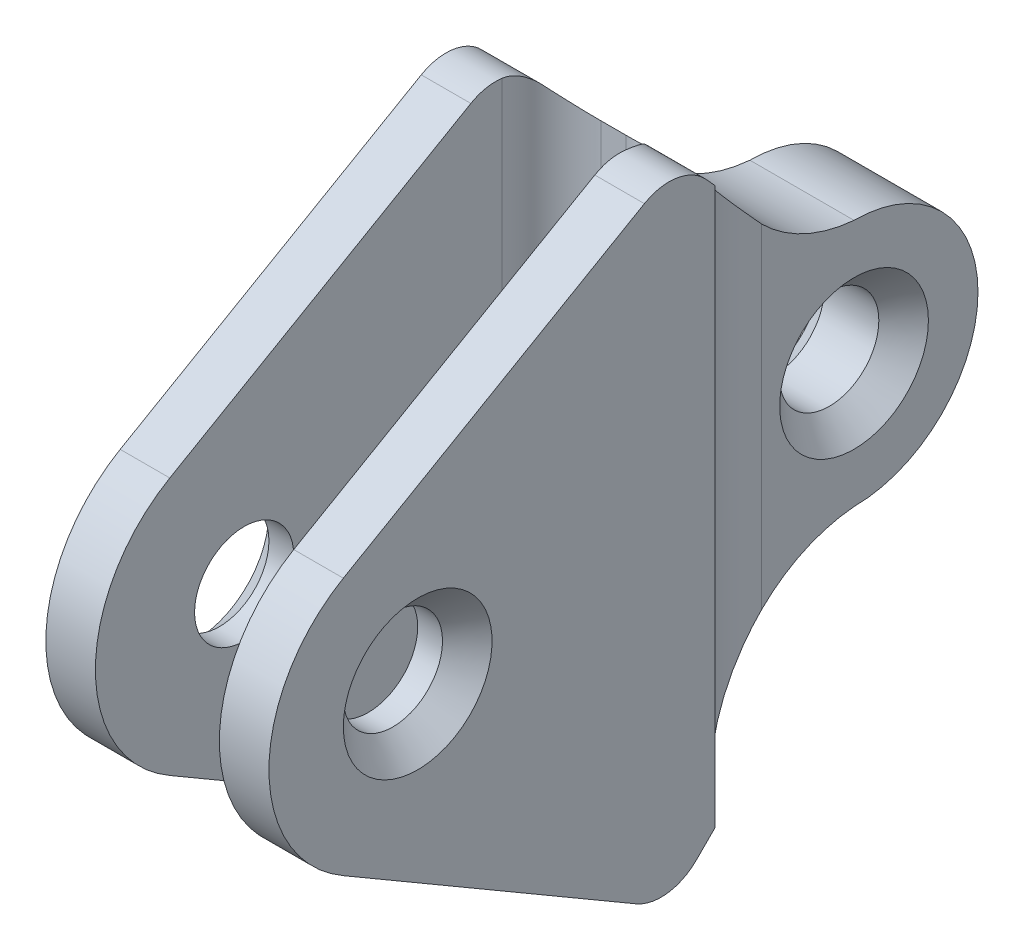
from build123d import *

# Parameters (mm, degrees)
BOSS_EXTRUDE1_DEPTH = 218
CUT_EXTRUDE1_DEPTH  = 218
CUT_EXTRUDE2_DEPTH  = 218
SKETCH6_R           = 10
CUT_EXTRUDE3_DEPTH  = 218
SKETCH7_R           = 10
CUT_EXTRUDE4_DEPTH  = 218
CHAMFER1_SIZE       = 5


with BuildPart() as part:
    # Sketch1 → Boss-Extrude1 (new body)
    with BuildSketch(Plane(origin=(0, 0, 0), x_dir=(1, 0, 0), z_dir=(0, 1, 0))):
        with BuildLine():
            Line((8, -63), (13, -63))
            ThreePointArc((13, -63), (20.071067812, -65.928932188), (23, -73))
            Line((23, -73), (23, -155))
            Line((23, -155), (33, -155))
            Line((33, -155), (33, -65))
            ThreePointArc((33, -65), (24.205505282, -55.89329221), (21, -43.645843496))
            Line((21, -43.645843496), (21, 0))
            Line((21, 0), (0, 0))
            Line((0, 0), (0, -43.645843496))
            ThreePointArc((0, -43.645843496), (-3.205505282, -55.89329221), (-12, -65))
            Line((-12, -65), (-12, -155))
            Line((-12, -155), (-2, -155))
            Line((-2, -155), (-2, -100.45062745))
            Line((-2, -100.45062745), (-2, -73))
            ThreePointArc((-2, -73), (0.928932188, -65.928932188), (8, -63))
        make_face()
    extrude(amount=BOSS_EXTRUDE1_DEPTH)

    # Sketch3 → Cut-Extrude1 (cut)
    with BuildSketch(Plane.ZY):
        with BuildLine():
            ThreePointArc((25, 138.56265757), (35.089663756, 141.253339953), (43.645843496, 147.239396639))
            Line((43.645843496, 147.239396639), (43.645843496, 218))
            Line((43.645843496, 218), (0, 218))
            Line((0, 218), (0, 113.56265757))
            ThreePointArc((0, 113.56265757), (7.32233047, 131.2403271), (25, 138.56265757))
        make_face()
        with BuildLine():
            ThreePointArc((25, 88.56265757), (7.32233047, 95.884988041), (0, 113.56265757))
            Line((0, 113.56265757), (0, 0))
            Line((0, 0), (43.645843496, 0))
            Line((43.645843496, 0), (43.645843496, 79.885918501))
            ThreePointArc((43.645843496, 79.885918501), (35.089663756, 85.871975187), (25, 88.56265757))
        make_face()
    extrude(amount=-CUT_EXTRUDE1_DEPTH, mode=Mode.SUBTRACT)

    # Sketch5 → Cut-Extrude2 (cut)
    with BuildSketch(Plane.ZY.offset(12)):
        with BuildLine():
            ThreePointArc((66.899192484, 172.697482901), (72.753620331, 175.835761562), (79.282746191, 174.613618416))
            Line((79.282746191, 174.613618416), (140, 139.558495585))
            ThreePointArc((140, 139.558495585), (150.980762114, 128.577733471), (155, 113.577733471))
            Line((155, 113.577733471), (155, 218))
            Line((155, 218), (65, 218))
            Line((65, 218), (65, 170.618220852))
            Line((65, 170.618220852), (66.899192484, 172.697482901))
        make_face()
        Polygon((43.645843496, 147.239396639), (65, 170.618220852), (65, 218), (43.645843496, 218), align=None)
        Polygon((65, 0), (65, 58.531761997), (43.645843496, 79.885918501), (43.645843496, 0), align=None)
        with BuildLine():
            Line((155, 0), (155, 113.577733471))
            ThreePointArc((155, 113.577733471), (150.980762114, 98.577733471), (140, 87.596971358))
            Line((140, 87.596971358), (80.972769589, 53.163585587))
            Line((80.972769589, 53.163585587), (80.895268222, 53.11837536))
            ThreePointArc((80.895268222, 53.11837536), (74.5900063, 51.864180784), (68.824200411, 54.707561586))
            Line((68.824200411, 54.707561586), (65, 58.531761997))
            Line((65, 58.531761997), (65, 0))
            Line((65, 0), (155, 0))
        make_face()
    extrude(amount=-CUT_EXTRUDE2_DEPTH, mode=Mode.SUBTRACT)

    # Sketch6 → Cut-Extrude3 (cut)
    with BuildSketch(Plane(origin=(33, 0, 0), x_dir=(0, 0, -1), z_dir=(1, 0, 0))):
        with Locations((-125, 113.577733471)):
            Circle(SKETCH6_R)
    extrude(amount=-CUT_EXTRUDE3_DEPTH, mode=Mode.SUBTRACT)

    # Sketch7 → Cut-Extrude4 (cut)
    with BuildSketch(Plane(origin=(21, 0, 0), x_dir=(0, 0, -1), z_dir=(1, 0, 0))):
        with Locations((-25, 113.56265757)):
            Circle(SKETCH7_R)
    extrude(amount=-CUT_EXTRUDE4_DEPTH, mode=Mode.SUBTRACT)

    # Chamfer1
    chamfer1_edges = [part.edges().sort_by_distance(p)[0] for p in [
        (-12, 113.577733471, 135),
        (33, 113.577733471, 135),
        (0, 113.56265757, 35),
        (21, 113.56265757, 35),
    ]]
    chamfer(chamfer1_edges, length=CHAMFER1_SIZE)


solid = part.part
